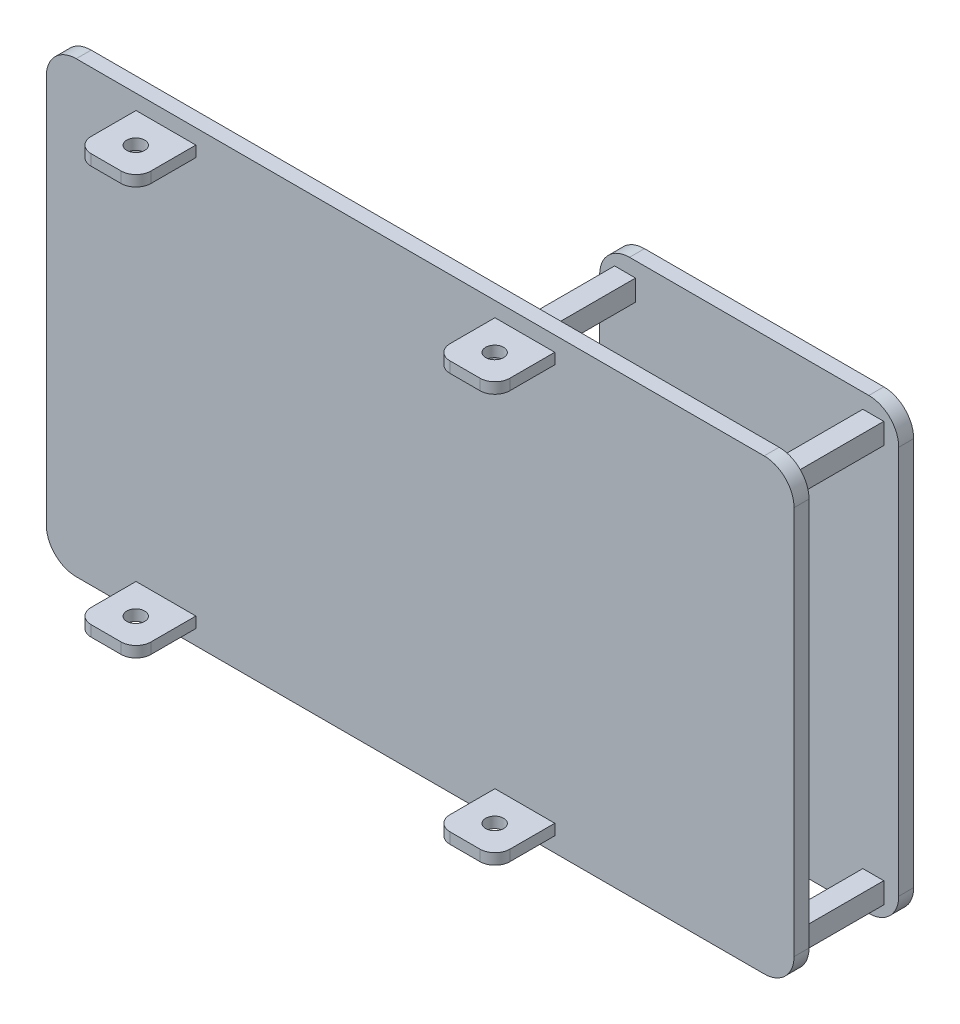
from build123d import *

# Parameters (mm, degrees)
SKETCH1_W               = 250
SKETCH1_H               = 150
BOSS_EXTRUDE1_DEPTH     = 5
SKETCH1_3_W             = 20
SKETCH1_3_H             = 3.633461532
BOSS_EXTRUDE2_DEPTH     = 25
CUT_EXTRUDE1_DEPTH      = 291.086194087
CUT_EXTRUDE1_DEPTH_BACK = 291.086194087
SKETCH2_R               = 3
FILLET1_R               = 5
FILLET2_R               = 10
SKETCH3_W               = 7
SKETCH3_H               = 7
BOSS_EXTRUDE3_DEPTH     = 30
BOSS_EXTRUDE5_DEPTH     = 5
FILLET4_R               = 10


with BuildPart() as part:
    # Sketch1 → Boss-Extrude1 (new body)
    with BuildSketch(Plane.XY):
        with Locations((125, 75)):
            Rectangle(SKETCH1_W, SKETCH1_H)
    extrude(amount=BOSS_EXTRUDE1_DEPTH)

    # Sketch1_3 → Boss-Extrude2 (add)
    with BuildSketch(Plane.XY):
        with Locations((160, 6.816730766)):
            Rectangle(SKETCH1_3_W, SKETCH1_3_H)
        with Locations((40, 143.183269234)):
            Rectangle(SKETCH1_3_W, SKETCH1_3_H)
        with Locations((160, 143.183269234)):
            Rectangle(SKETCH1_3_W, SKETCH1_3_H)
        with Locations((40, 6.816730766)):
            Rectangle(SKETCH1_3_W, SKETCH1_3_H)
    extrude(amount=BOSS_EXTRUDE2_DEPTH)

    # Sketch2 → Cut-Extrude1 (cut, two sides: drawn at the far end of the back side and taken through both)
    with BuildSketch(Plane.XZ.offset(-5).offset(-CUT_EXTRUDE1_DEPTH_BACK)):
        with Locations((40, 15.1)):
            Circle(SKETCH2_R)
        with Locations((160, 15.1)):
            Circle(SKETCH2_R)
    extrude(amount=CUT_EXTRUDE1_DEPTH + CUT_EXTRUDE1_DEPTH_BACK, mode=Mode.SUBTRACT)

    # Fillet1
    fillet1_edges = [part.edges().sort_by_distance(p)[0] for p in [
        (30, 6.816730766, 25),
        (50, 6.816730766, 25),
        (150, 6.816730766, 25),
        (170, 6.816730766, 25),
        (170, 143.183269234, 25),
        (150, 143.183269234, 25),
        (50, 143.183269234, 25),
        (30, 143.183269234, 25),
    ]]
    fillet(fillet1_edges, radius=FILLET1_R)

    # Fillet2
    fillet2_edges = [part.edges().sort_by_distance(p)[0] for p in [
        (250, 150, 2.5),
        (250, 0, 2.5),
        (0, 150, 2.5),
        (0, 0, 2.5),
    ]]
    fillet(fillet2_edges, radius=FILLET2_R)

    # Sketch3 → Boss-Extrude3 (add)
    with BuildSketch(Plane(origin=(0, 0, 0), x_dir=(-1, 0, 0), z_dir=(0, 0, -1))):
        with Locations((-241.5, 141.5)):
            Rectangle(SKETCH3_W, SKETCH3_H)
        with Locations((-241.5, 8.5)):
            Rectangle(SKETCH3_W, SKETCH3_H)
        with Locations((-158.5, 8.5)):
            Rectangle(SKETCH3_W, SKETCH3_H)
        with Locations((-158.5, 141.5)):
            Rectangle(SKETCH3_W, SKETCH3_H)
    extrude(amount=BOSS_EXTRUDE3_DEPTH)

    # Sketch10 → Boss-Extrude5 (add)
    with BuildSketch(Plane(origin=(0, 0, -30), x_dir=(-1, 0, 0), z_dir=(0, 0, -1))):
        with BuildLine():
            Line((-150, 150), (-150, 0))
            Line((-150, 0), (-240, 0))
            ThreePointArc((-240, 0), (-247.071067812, 2.928932188), (-250, 10))
            Line((-250, 10), (-250, 140))
            ThreePointArc((-250, 140), (-247.071067812, 147.071067812), (-240, 150))
            Line((-240, 150), (-150, 150))
        make_face()
    extrude(amount=BOSS_EXTRUDE5_DEPTH)

    # Fillet4
    fillet4_edges = [part.edges().sort_by_distance(p)[0] for p in [
        (150, 0, -32.5),
        (150, 150, -32.5),
    ]]
    fillet(fillet4_edges, radius=FILLET4_R)


solid = part.part
